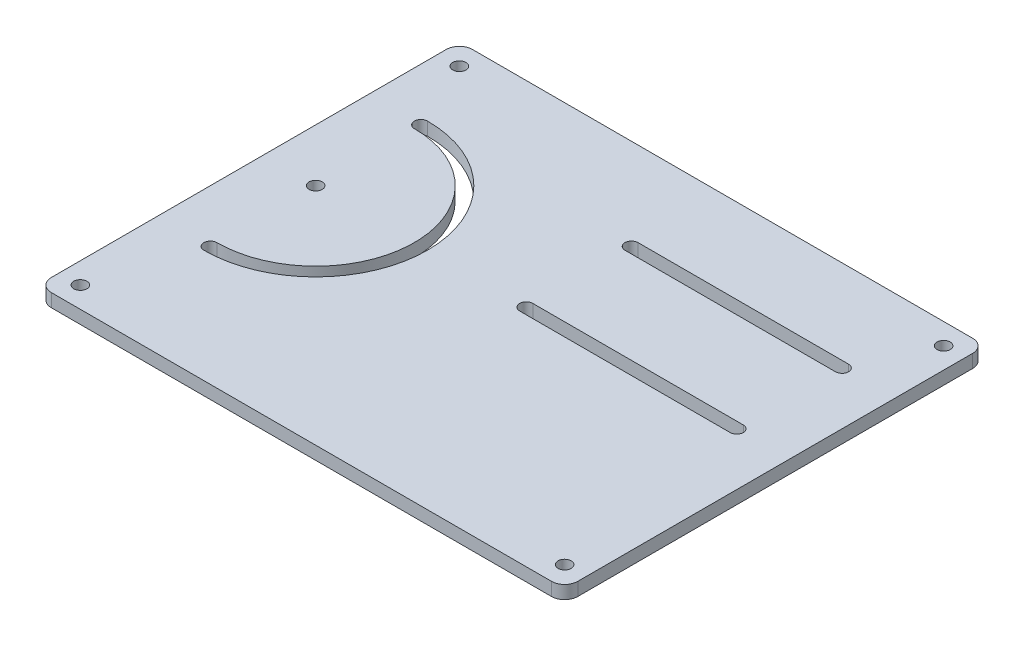
from build123d import *

# Parameters (mm, degrees)
SKETCH1_R           = 1.5875
BOSS_EXTRUDE1_DEPTH = 3.175


with BuildPart() as part:
    # Sketch1 → Boss-Extrude1 (new body)
    with BuildSketch(Plane(origin=(0, 0, 0), x_dir=(1, 0, 0), z_dir=(0, 1, 0))):
        with BuildLine():
            Line((3.175, 0), (123.825, 0))
            ThreePointArc((123.825, 0), (126.07006403, 0.92993597), (127, 3.175))
            Line((127, 3.175), (127, 98.425))
            ThreePointArc((127, 98.425), (126.07006403, 100.67006403), (123.825, 101.6))
            Line((123.825, 101.6), (3.175, 101.6))
            ThreePointArc((3.175, 101.6), (0.92993597, 100.67006403), (0, 98.425))
            Line((0, 98.425), (0, 3.175))
            ThreePointArc((0, 3.175), (0.92993597, 0.92993597), (3.175, 0))
        make_face()
        with Locations((12.7, 54.229148011)):
            Circle(SKETCH1_R, mode=Mode.SUBTRACT)
        with Locations((5.08, 96.52)):
            Circle(SKETCH1_R, mode=Mode.SUBTRACT)
        with Locations((5.08, 5.08)):
            Circle(SKETCH1_R, mode=Mode.SUBTRACT)
        with Locations((121.92, 96.52)):
            Circle(SKETCH1_R, mode=Mode.SUBTRACT)
        with Locations((121.92, 5.08)):
            Circle(SKETCH1_R, mode=Mode.SUBTRACT)
        with BuildLine():
            Line((63.5, 81.216648011), (114.3, 81.216648011))
            ThreePointArc((114.3, 81.216648011), (115.8875, 79.629148011), (114.3, 78.041648011))
            Line((114.3, 78.041648011), (63.5, 78.041648011))
            ThreePointArc((63.5, 78.041648011), (61.9125, 79.629148011), (63.5, 81.216648011))
        make_face(mode=Mode.SUBTRACT)
        with BuildLine():
            Line((63.5, 55.816648011), (114.3, 55.816648011))
            ThreePointArc((114.3, 55.816648011), (115.8875, 54.229148011), (114.3, 52.641648011))
            Line((114.3, 52.641648011), (63.5, 52.641648011))
            ThreePointArc((63.5, 52.641648011), (61.9125, 54.229148011), (63.5, 55.816648011))
        make_face(mode=Mode.SUBTRACT)
        with BuildLine():
            ThreePointArc((12.7, 78.041648011), (36.5125, 54.229148011), (12.7, 30.416648011))
            ThreePointArc((12.7, 30.416648011), (11.1125, 28.829148011), (12.7, 27.241648011))
            ThreePointArc((12.7, 27.241648011), (39.6875, 54.229148011), (12.7, 81.216648011))
            ThreePointArc((12.7, 81.216648011), (11.1125, 79.629148011), (12.7, 78.041648011))
        make_face(mode=Mode.SUBTRACT)
    extrude(amount=BOSS_EXTRUDE1_DEPTH)


solid = part.part
